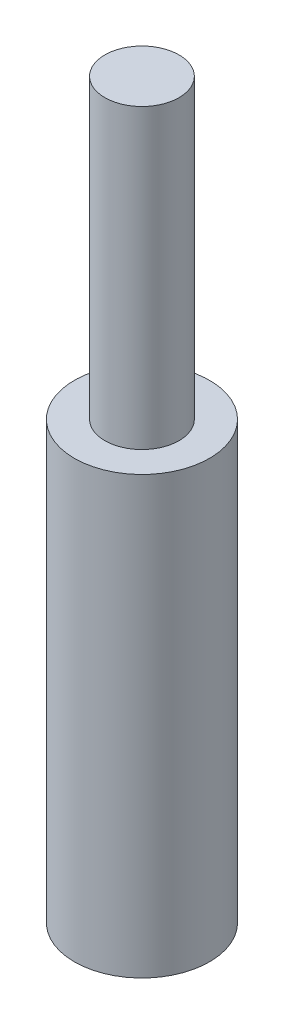
from build123d import *

# Parameters (mm, degrees)
SKETCH2_R           = 1.55
BOSS_EXTRUDE1_DEPTH = 10
SKETCH3_R           = 0.85
BOSS_EXTRUDE2_DEPTH = 6.812859237


with BuildPart() as part:
    # Sketch2 → Boss-Extrude1 (new body)
    with BuildSketch(Plane(origin=(0, 0, 0), x_dir=(1, 0, 0), z_dir=(0, 1, 0))):
        Circle(SKETCH2_R)
    extrude(amount=BOSS_EXTRUDE1_DEPTH)

    # Sketch3 → Boss-Extrude2 (add)
    with BuildSketch(Plane(origin=(0, 10, 0), x_dir=(1, 0, 0), z_dir=(0, 1, 0))):
        Circle(SKETCH3_R)
    extrude(amount=BOSS_EXTRUDE2_DEPTH)


solid = part.part
